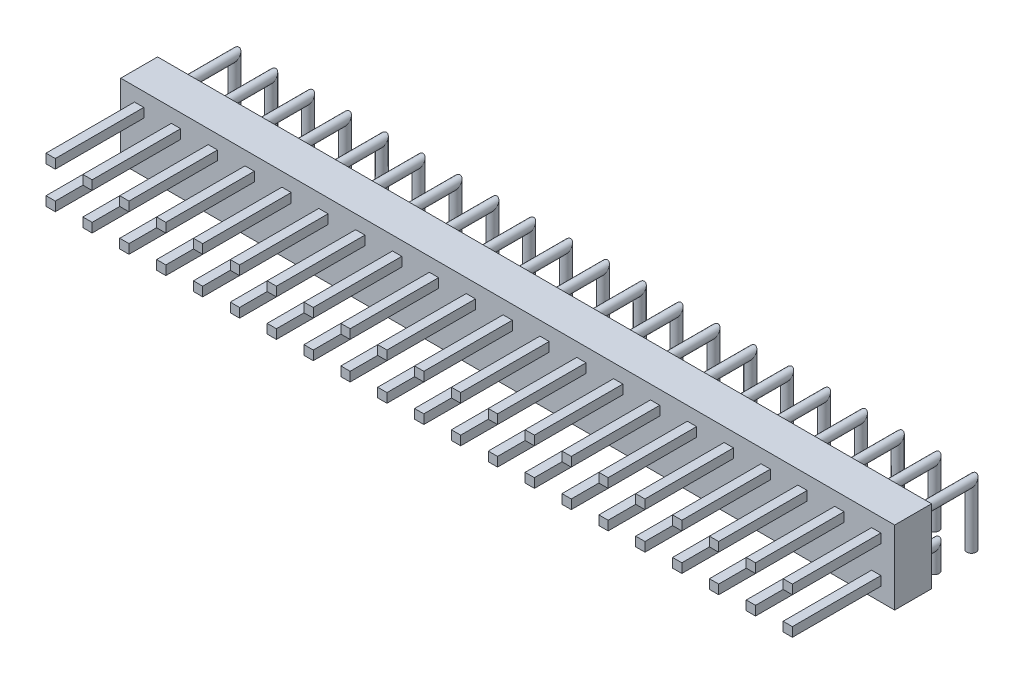
from build123d import *

# Parameters (mm, degrees)
SKETCH1_W           = 2.54
SKETCH1_H           = 2.54
BOSS_EXTRUDE1_DEPTH = 2.54
SKETCH2_W           = 0.64
SKETCH2_H           = 0.64
BOSS_EXTRUDE3_DEPTH = 6.1
SWEEP2_PROFILE_R    = 0.32
SWEEP3_PROFILE_R    = 0.32
LPATTERN1_COUNT     = 21
LPATTERN1_PITCH     = 2.54


with BuildPart() as part:
    # Sketch1 → Boss-Extrude1 (new body)
    with BuildSketch(Plane.XY):
        with Locations((1.27, 3.81)):
            Rectangle(SKETCH1_W, SKETCH1_H)
        with Locations((1.27, 1.27)):
            Rectangle(SKETCH1_W, SKETCH1_H)
    boss_extrude1 = extrude(amount=BOSS_EXTRUDE1_DEPTH)

    # Sketch2 → Boss-Extrude3 (add)
    with BuildSketch(Plane.XY.offset(2.54)):
        with Locations((1.27, 1.27)):
            Rectangle(SKETCH2_W, SKETCH2_H)
        with Locations((1.27, 3.81)):
            Rectangle(SKETCH2_W, SKETCH2_H)
    boss_extrude3 = extrude(amount=BOSS_EXTRUDE3_DEPTH)

    # Sweep2: sweep along a path in Sketch14
    with BuildLine(Plane(origin=(1.27, 0, 0), x_dir=(0, 0, -1), z_dir=(1, 0, 0))) as sweep2_path:
        Line((0, 1.27), (1.48, 1.27))
        Line((1.48, 1.27), (1.48, -0.3))
    # Sweep2 profile (on start of the path) → Sweep2 (sweep)
    with BuildSketch(Plane(origin=(1.27, 1.27, 0), x_dir=(0, -1, 0), z_dir=(0, 0, -1))):
        Circle(SWEEP2_PROFILE_R)
    sweep2 = sweep(path=sweep2_path.line, transition=Transition.RIGHT)

    # Sweep3: sweep along a path in Sketch21
    with BuildLine(Plane(origin=(1.27, 0, 0), x_dir=(0, 0, -1), z_dir=(1, 0, 0))) as sweep3_path:
        Line((4.02, -0.3), (4.02, 3.81))
        Line((4.02, 3.81), (0, 3.81))
    # Sweep3 profile (on start of the path) → Sweep3 (sweep)
    with BuildSketch(Plane(origin=(1.27, -0.3, -4.02), x_dir=(0, 0, 1), z_dir=(0, 1, 0))):
        Circle(SWEEP3_PROFILE_R)
    sweep3 = sweep(path=sweep3_path.line, transition=Transition.RIGHT)

    # LPattern1: Boss-Extrude1, Boss-Extrude3, Sweep2, Sweep3 ×21
    with Locations(*[(i * LPATTERN1_PITCH, 0, 0) for i in range(1, LPATTERN1_COUNT)]):
        add(boss_extrude1)
        add(boss_extrude3)
        add(sweep2)
        add(sweep3)


solid = part.part
